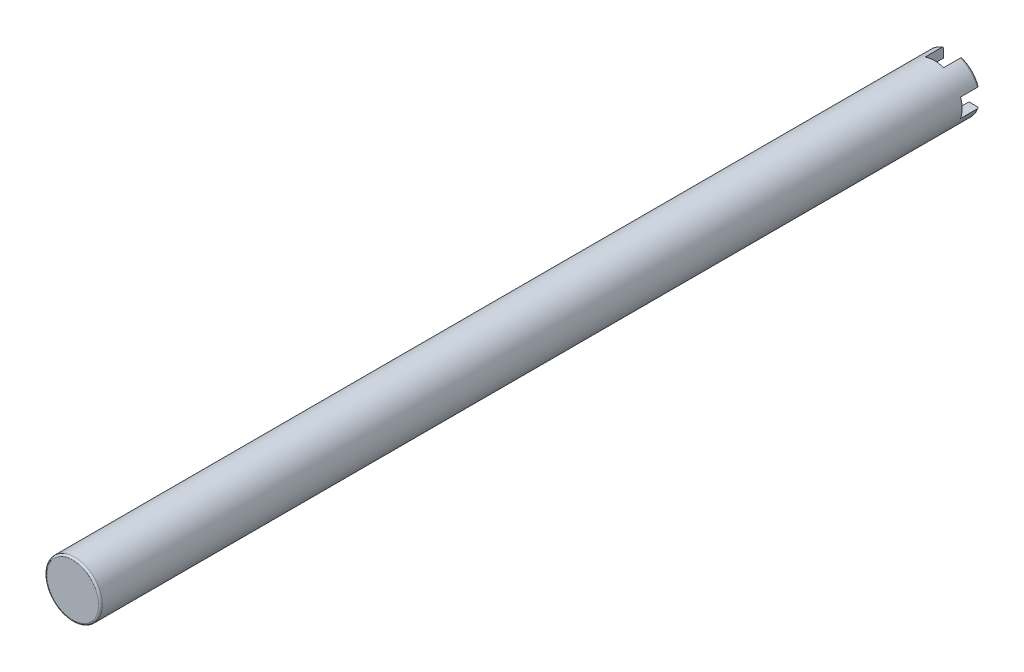
from build123d import *

# Parameters (mm, degrees)
SKETCH1_R           = 38.1
BOSS_EXTRUDE1_DEPTH = 1206.5
FILLET1_R           = 2.54
FILLET2_R           = 2.54
CUT_EXTRUDE2_DEPTH  = 25.4
SKETCH2_R           = 25.4
CUT_EXTRUDE1_DEPTH  = 609.6


with BuildPart() as part:
    # Sketch1 → Boss-Extrude1 (new body)
    with BuildSketch(Plane.XY):
        Circle(SKETCH1_R)
    extrude(amount=BOSS_EXTRUDE1_DEPTH)

    # Fillet1
    fillet1_edges = [part.edges().sort_by_distance(p)[0] for p in [
        (-38.1, 0, 1206.5),
    ]]
    fillet(fillet1_edges, radius=FILLET1_R)

    # Fillet2
    fillet2_edges = [part.edges().sort_by_distance(p)[0] for p in [
        (-38.1, 0, 0),
    ]]
    fillet(fillet2_edges, radius=FILLET2_R)

    # Sketch3 → Cut-Extrude2 (cut)
    with BuildSketch(Plane(origin=(0, 0, 0), x_dir=(-1, 0, 0), z_dir=(0, 0, -1))):
        Polygon((12.7, 12.7), (64.136774618, 12.7), (64.136774618, -12.7), (12.7, -12.7), (12.7, -42.915047722), (-12.7, -42.915047722), (-12.7, -12.7), (-64.765566526, -12.7), (-64.765566526, 12.7), (-12.7, 12.7), (-12.7, 40.714276044), (12.7, 40.714276044), align=None)
    extrude(amount=-CUT_EXTRUDE2_DEPTH, mode=Mode.SUBTRACT)

    # Sketch2 → Cut-Extrude1 (cut)
    with BuildSketch(Plane(origin=(0, 0, 0), x_dir=(-1, 0, 0), z_dir=(0, 0, -1))):
        Circle(SKETCH2_R)
    extrude(amount=-CUT_EXTRUDE1_DEPTH, mode=Mode.SUBTRACT)


solid = part.part
